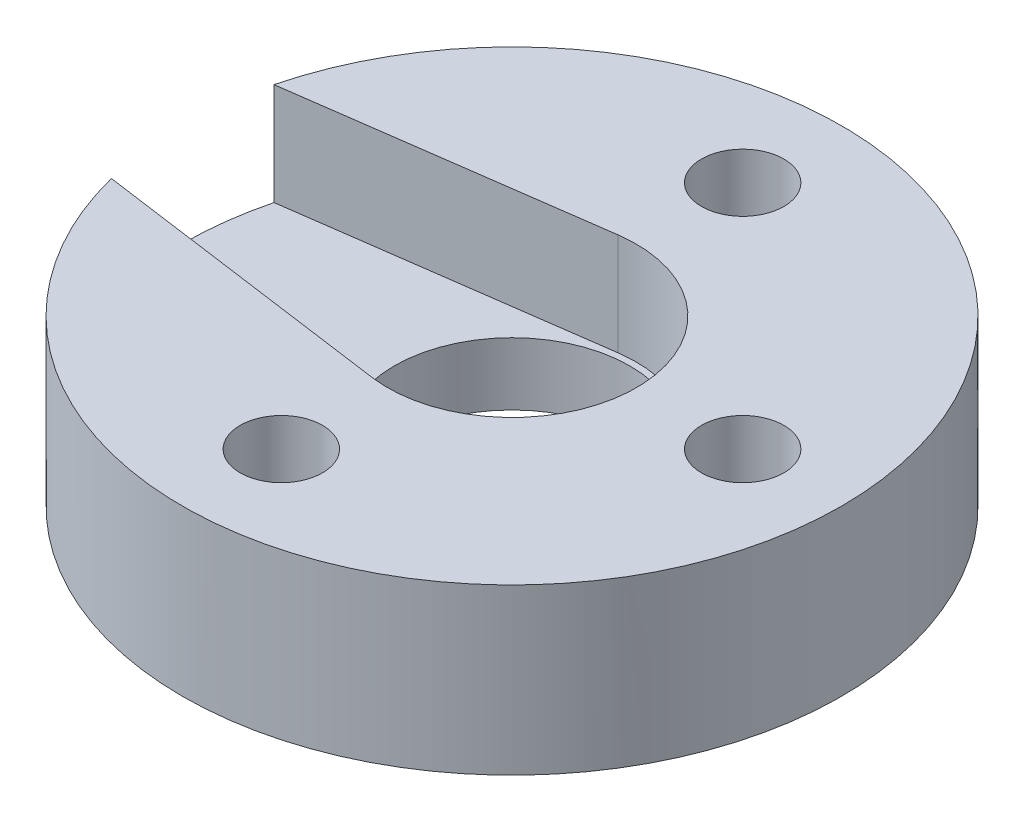
from build123d import *

# Parameters (mm, degrees)
SKETCH1_R                       = 10
BOSS_EXTRUDE1_DEPTH             = 5
TAP_DRILL_FOR_M3X0_5_TAP1_D     = 2.5
TAP_DRILL_FOR_M3X0_5_TAP1_DEPTH = 38.1
CIRPATTERN1_COUNT               = 4
F_14_0_182_DIAMETER_HOLE1_D     = 7.1499984
CUT_EXTRUDE2_DEPTH              = 3.1


with BuildPart() as part:
    # Sketch1 → Boss-Extrude1 (new body)
    with BuildSketch(Plane(origin=(0, 0, 0), x_dir=(1, 0, 0), z_dir=(0, 1, 0))):
        Circle(SKETCH1_R)
    extrude(amount=BOSS_EXTRUDE1_DEPTH)

    # Tap Drill for M3x0.5 Tap1
    with Locations(Plane(origin=(0, 5, 0), x_dir=(1, 0, 0), z_dir=(0, 1, 0))):
        with Locations((7, 0)):
            tap_drill_for_m3x0_5_tap1 = Hole(TAP_DRILL_FOR_M3X0_5_TAP1_D / 2, depth=TAP_DRILL_FOR_M3X0_5_TAP1_DEPTH)

    # CirPattern1: Tap Drill for M3x0.5 Tap1 ×4 about axis, 1 skipped
    cirpattern1_axis = Axis((0, 5, 0), (0, -1, 0))
    add([tap_drill_for_m3x0_5_tap1.rotate(cirpattern1_axis, i * 360 / CIRPATTERN1_COUNT) for i in range(1, CIRPATTERN1_COUNT) if i not in (2,)], mode=Mode.SUBTRACT)

    # 14 _0.182_ Diameter Hole1 (through all)
    with Locations(Plane(origin=(0, 5, 0), x_dir=(1, 0, 0), z_dir=(0, 1, 0))):
        with Locations((0, 0)):
            Hole(F_14_0_182_DIAMETER_HOLE1_D / 2)

    # Sketch9 → Cut-Extrude2 (cut)
    with BuildSketch(Plane(origin=(0, 5, 0), x_dir=(1, 0, 0), z_dir=(0, 1, 0))):
        with BuildLine():
            Line((-0.518585505, 3.739209547), (-12.660050371, 2.055327537))
            ThreePointArc((-12.660050371, 2.055327537), (-14.45, 0), (-12.660050371, -2.055327537))
            Line((-12.660050371, -2.055327537), (-0.518585505, -3.739209547))
            ThreePointArc((-0.518585505, -3.739209547), (3.7749992, 0), (-0.518585505, 3.739209547))
        make_face()
    extrude(amount=-CUT_EXTRUDE2_DEPTH, mode=Mode.SUBTRACT)


solid = part.part
